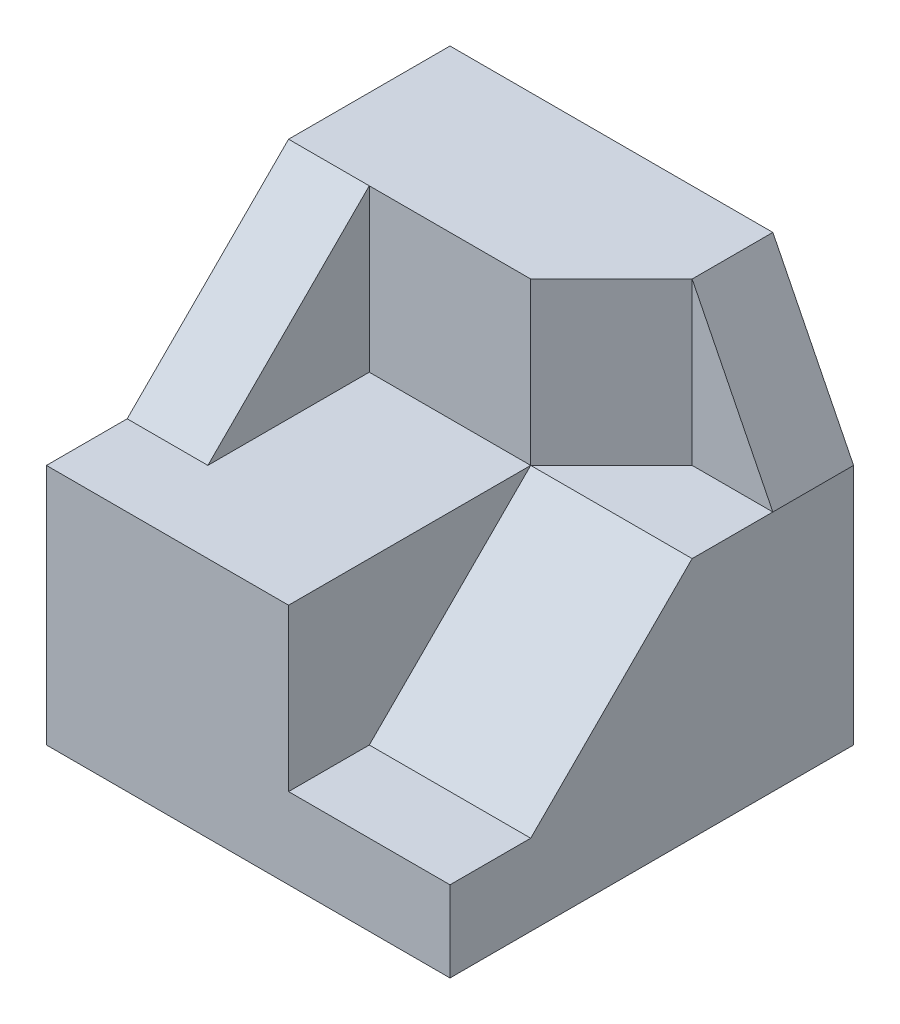
from build123d import *

# Parameters (mm, degrees)
SKETCH1_W           = 5
SKETCH1_H           = 5
BOSS_EXTRUDE1_DEPTH = 5
CUT_EXTRUDE1_DEPTH  = 2
CUT_EXTRUDE7_DEPTH  = 1
SKETCH6_W           = 2
SKETCH6_H           = 4
CUT_EXTRUDE13_DEPTH = 1
CUT_EXTRUDE14_DEPTH = 2
CUT_EXTRUDE16_DEPTH = 3
CUT_EXTRUDE17_DEPTH = 2


with BuildPart() as part:
    # Sketch1 → Boss-Extrude1 (new body)
    with BuildSketch(Plane.XY):
        Rectangle(SKETCH1_W, SKETCH1_H)
    extrude(amount=BOSS_EXTRUDE1_DEPTH)

    # Sketch2 → Cut-Extrude1 (cut)
    with BuildSketch(Plane(origin=(0, 2.5, 0), x_dir=(1, 0, 0), z_dir=(0, 1, 0))):
        Polygon((-2.5, -5), (0.5, -5), (0.5, -2), (-1.5, -2), (-1.5, -4), (-2.5, -4), align=None)
    extrude(amount=-CUT_EXTRUDE1_DEPTH, mode=Mode.SUBTRACT)

    # Sketch3 → Cut-Extrude7 (cut)
    with BuildSketch(Plane.ZY.offset(2.5)):
        Polygon((4, 0.5), (2, 2.5), (4, 2.5), align=None)
    extrude(amount=-CUT_EXTRUDE7_DEPTH, mode=Mode.SUBTRACT)

    # Sketch6 → Cut-Extrude13 (cut)
    with BuildSketch(Plane.XY.offset(5)):
        with Locations((1.5, 0.5)):
            Rectangle(SKETCH6_W, SKETCH6_H)
    extrude(amount=-CUT_EXTRUDE13_DEPTH, mode=Mode.SUBTRACT)

    # Sketch7 → Cut-Extrude14 (cut)
    with BuildSketch(Plane(origin=(2.5, 0, 0), x_dir=(0, 0, -1), z_dir=(1, 0, 0))):
        Polygon((-4, 2.5), (-2, 2.5), (-2, 0.5), (-4, -1.5), align=None)
    extrude(amount=-CUT_EXTRUDE14_DEPTH, mode=Mode.SUBTRACT)

    # Sketch8 → Cut-Extrude16 (cut, through all)
    with BuildSketch(Plane.XY.offset(2)):
        Polygon((2.5, 2.5), (1.5, 2.5), (2.5, 0.5), align=None)
    extrude(amount=-CUT_EXTRUDE16_DEPTH, mode=Mode.SUBTRACT)

    # Sketch10 → Cut-Extrude17 (cut)
    with BuildSketch(Plane(origin=(0, 2.5, 0), x_dir=(1, 0, 0), z_dir=(0, 1, 0))):
        Polygon((2.5, -2), (2.5, -1), (1.5, -1), (0.5, -2), align=None)
    extrude(amount=-CUT_EXTRUDE17_DEPTH, mode=Mode.SUBTRACT)


solid = part.part
